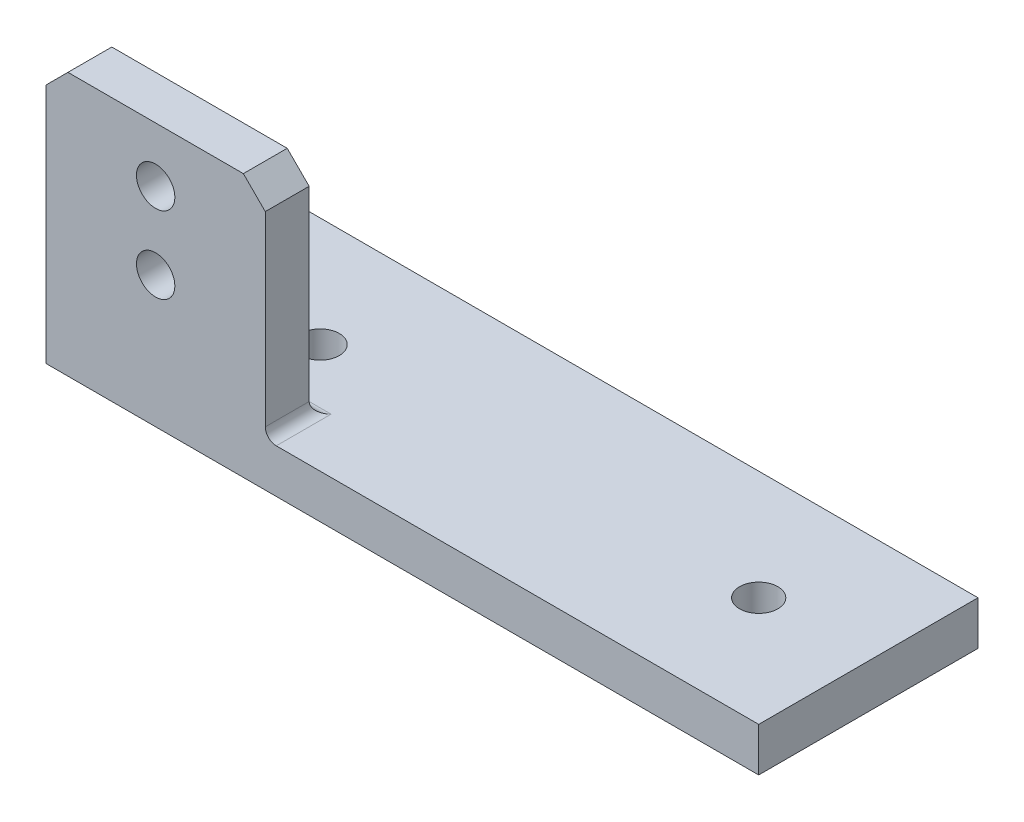
from build123d import *

# Parameters (mm, degrees)
SCHIZZO1_W                   = 65
SCHIZZO1_H                   = 4
ESTRUSIONE_ESTRUSIONE1_DEPTH = 20
SCHIZZO2_W                   = 20
SCHIZZO2_H                   = 4
ESTRUSIONE_ESTRUSIONE2_DEPTH = 20
TAGLIO_ESTRUSIONE1_REACH     = 6
SCHIZZO6_R                   = 1.75
TAGLIO_ESTRUSIONE2_REACH     = 6
SCHIZZO7_R                   = 1.75
RACCORDO1_R                  = 1
RACCORDO2_R                  = 1
SMUSSO1_SIZE                 = 2
SMUSSO3_SIZE                 = 2


with BuildPart() as part:
    # Schizzo1 → Estrusione-Estrusione1 (new body)
    with BuildSketch(Plane.XY):
        with Locations((32.5, 2)):
            Rectangle(SCHIZZO1_W, SCHIZZO1_H)
    extrude(amount=ESTRUSIONE_ESTRUSIONE1_DEPTH)

    # Schizzo2 → Estrusione-Estrusione2 (add)
    with BuildSketch(Plane(origin=(0, 4, 0), x_dir=(1, 0, 0), z_dir=(0, 1, 0))):
        with Locations((10, -18)):
            Rectangle(SCHIZZO2_W, SCHIZZO2_H)
    extrude(amount=ESTRUSIONE_ESTRUSIONE2_DEPTH)

    # Schizzo6 → Taglio-Estrusione1 (cut, up to next)
    with BuildSketch(Plane(origin=(0, 4, 0), x_dir=(1, 0, 0), z_dir=(0, 1, 0)), mode=Mode.PRIVATE) as taglio_estrusione1_sk1:
        with Locations((15, -10)):
            Circle(SCHIZZO6_R)
    taglio_estrusione1_tool1 = extrude(taglio_estrusione1_sk1.sketch, amount=-TAGLIO_ESTRUSIONE1_REACH, mode=Mode.PRIVATE) & part.part
    add(taglio_estrusione1_tool1.solids().sort_by_distance((15, 4, 10))[0], mode=Mode.SUBTRACT)
    # Schizzo6 → Taglio-Estrusione1 (cut, up to next)
    with BuildSketch(Plane(origin=(0, 4, 0), x_dir=(1, 0, 0), z_dir=(0, 1, 0)), mode=Mode.PRIVATE) as taglio_estrusione1_sk2:
        with Locations((55, -10)):
            Circle(SCHIZZO6_R)
    taglio_estrusione1_tool2 = extrude(taglio_estrusione1_sk2.sketch, amount=-TAGLIO_ESTRUSIONE1_REACH, mode=Mode.PRIVATE) & part.part
    add(taglio_estrusione1_tool2.solids().sort_by_distance((55, 4, 10))[0], mode=Mode.SUBTRACT)

    # Schizzo7 → Taglio-Estrusione2 (cut, up to next)
    with BuildSketch(Plane(origin=(0, 0, 16), x_dir=(-1, 0, 0), z_dir=(0, 0, -1)), mode=Mode.PRIVATE) as taglio_estrusione2_sk1:
        with Locations((-10, 19)):
            Circle(SCHIZZO7_R)
    taglio_estrusione2_tool1 = extrude(taglio_estrusione2_sk1.sketch, amount=-TAGLIO_ESTRUSIONE2_REACH, mode=Mode.PRIVATE) & part.part
    add(taglio_estrusione2_tool1.solids().sort_by_distance((10, 19, 16))[0], mode=Mode.SUBTRACT)
    # Schizzo7 → Taglio-Estrusione2 (cut, up to next)
    with BuildSketch(Plane(origin=(0, 0, 16), x_dir=(-1, 0, 0), z_dir=(0, 0, -1)), mode=Mode.PRIVATE) as taglio_estrusione2_sk2:
        with Locations((-10, 12)):
            Circle(SCHIZZO7_R)
    taglio_estrusione2_tool2 = extrude(taglio_estrusione2_sk2.sketch, amount=-TAGLIO_ESTRUSIONE2_REACH, mode=Mode.PRIVATE) & part.part
    add(taglio_estrusione2_tool2.solids().sort_by_distance((10, 12, 16))[0], mode=Mode.SUBTRACT)

    # Raccordo1
    raccordo1_edges = [part.edges().sort_by_distance(p)[0] for p in [
        (10, 4, 16),
    ]]
    fillet(raccordo1_edges, radius=RACCORDO1_R)

    # Raccordo2
    raccordo2_edges = [part.edges().sort_by_distance(p)[0] for p in [
        (20, 4, 18),
    ]]
    fillet(raccordo2_edges, radius=RACCORDO2_R)

    # Smusso1
    smusso1_edges = [part.edges().sort_by_distance(p)[0] for p in [
        (0, 24, 18),
        (20, 24, 18),
    ]]
    chamfer(smusso1_edges, length=SMUSSO1_SIZE)

    # Smusso3
    smusso3_edges = [part.edges().sort_by_distance(p)[0] for p in [
        (0, 2, 0),
    ]]
    chamfer(smusso3_edges, length=SMUSSO3_SIZE)


solid = part.part
